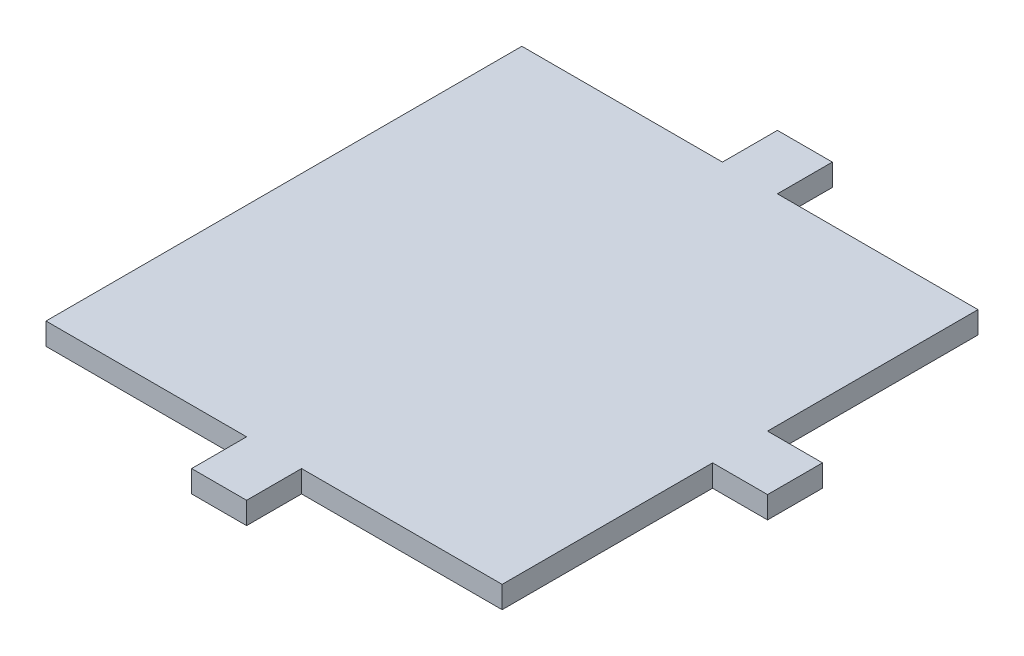
from build123d import *

# Parameters (mm, degrees)
SKETCH1_W           = 7
SKETCH1_H           = 7
BOSS_EXTRUDE1_DEPTH = 3
SKETCH3_W           = 10
SKETCH3_H           = 10
BOSS_EXTRUDE2_DEPTH = 15
BOSS_EXTRUDE4_DEPTH = 4


with BuildPart() as part:
    # Sketch1 → Boss-Extrude1 (new body)
    with BuildSketch(Plane(origin=(0, 0, 0), x_dir=(1, 0, 0), z_dir=(0, 1, 0))):
        Rectangle(SKETCH1_W, SKETCH1_H)
    extrude(amount=BOSS_EXTRUDE1_DEPTH)

    # Sketch3 → Boss-Extrude2 (add)
    with BuildSketch(Plane(origin=(0, 3, 0), x_dir=(1, 0, 0), z_dir=(0, 1, 0))):
        Rectangle(SKETCH3_W, SKETCH3_H)
    extrude(amount=BOSS_EXTRUDE2_DEPTH)

    # Sketch4 → Boss-Extrude4 (add)
    with BuildSketch(Plane(origin=(0, 18, 0), x_dir=(1, 0, 0), z_dir=(0, 1, 0))):
        Polygon((10.857439738, 43.294473551), (10.857439738, 53.294473551), (0.857439738, 53.294473551), (0.857439738, 43.294473551), (-35.642560262, 43.294473551), (-35.642560262, -43.294473551), (0.857439738, -43.294473551), (0.857439738, -53.294473551), (10.857439738, -53.294473551), (10.857439738, -43.294473551), (47.357439738, -43.294473551), (47.357439738, -5), (57.357439738, -5), (57.357439738, 5), (47.357439738, 5), (47.357439738, 43.294473551), align=None)
    extrude(amount=BOSS_EXTRUDE4_DEPTH)


solid = part.part
